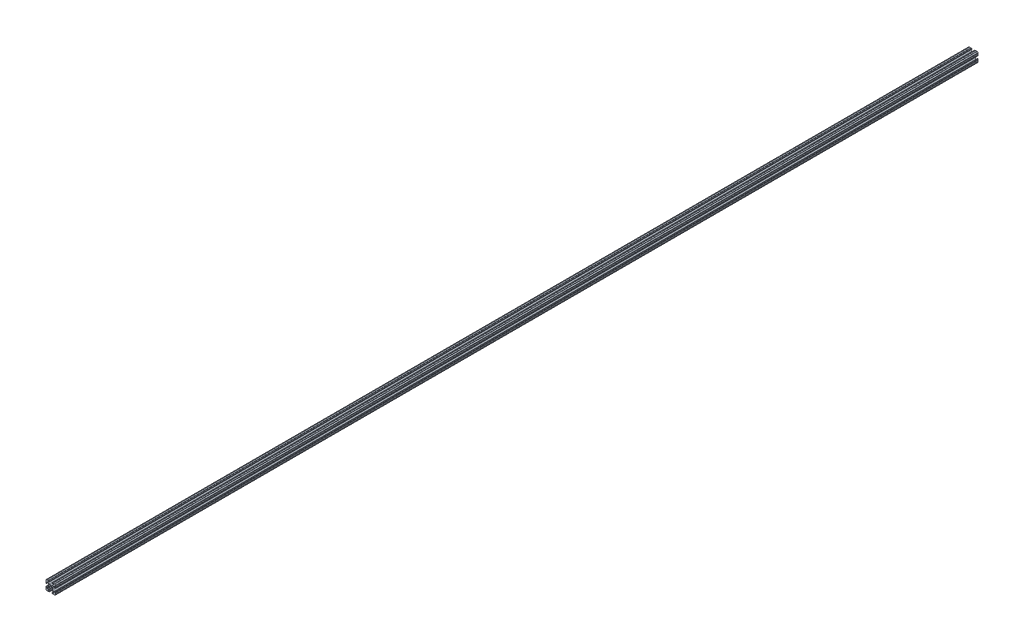
from build123d import *

# Parameters (mm, degrees)
SKETCH1_R           = 2.6035
BOSS_EXTRUDE1_DEPTH = 2463.8


with BuildPart() as part:
    # Sketch1 → Boss-Extrude1 (new body)
    with BuildSketch(Plane.XY):
        with BuildLine():
            Line((-1.709253557, -4.4958), (1.709253557, -4.4958))
            ThreePointArc((1.709253557, -4.4958), (2.922936451, -4.736929036), (3.952270251, -5.423690499))
            Line((3.952270251, -5.423690499), (7.179650497, -8.645192506))
            ThreePointArc((7.179650497, -8.645192506), (7.41473083, -9.822813117), (6.416408329, -10.4902))
            Line((6.416408329, -10.4902), (4.287512407, -10.4902))
            ThreePointArc((4.287512407, -10.4902), (3.54574862, -10.79744862), (3.2385, -11.539212407))
            Line((3.2385, -11.539212407), (3.2385, -11.650987593))
            ThreePointArc((3.2385, -11.650987593), (3.54574862, -12.39275138), (4.287512407, -12.7))
            Line((4.287512407, -12.7), (5.317126718, -12.7))
            ThreePointArc((5.317126718, -12.7), (5.825126718, -12.192), (6.333126718, -12.7))
            Line((6.333126718, -12.7), (9.550443118, -12.7))
            ThreePointArc((9.550443118, -12.7), (10.058366869, -12.192000006), (10.566443095, -12.699847501))
            ThreePointArc((10.566443095, -12.699847501), (12.082537762, -12.08250727), (12.699846982, -10.566399977))
            ThreePointArc((12.699846982, -10.566399977), (12.192000006, -10.058323491), (12.7, -9.5504))
            Line((12.7, -9.5504), (12.7, -6.3330836))
            ThreePointArc((12.7, -6.3330836), (12.192, -5.8250836), (12.7, -5.3170836))
            Line((12.7, -5.3170836), (12.7, -4.287469289))
            ThreePointArc((12.7, -4.287469289), (12.39275138, -3.545705502), (11.650987593, -3.238456882))
            Line((11.650987593, -3.238456882), (11.539212407, -3.238456882))
            ThreePointArc((11.539212407, -3.238456882), (10.79744862, -3.545705502), (10.4902, -4.287469289))
            Line((10.4902, -4.287469289), (10.4902, -6.402089023))
            ThreePointArc((10.4902, -6.402089023), (9.856505071, -7.351067942), (8.737131347, -7.129408934))
            Line((8.737131347, -7.129408934), (5.441005833, -3.840816462))
            ThreePointArc((5.441005833, -3.840816462), (4.750877967, -2.809883091), (4.5085, -1.593185507))
            Line((4.5085, -1.593185507), (4.5085, 1.593185507))
            ThreePointArc((4.5085, 1.593185507), (4.750877967, 2.809883091), (5.441005833, 3.840816462))
            Line((5.441005833, 3.840816462), (8.737131347, 7.129408934))
            ThreePointArc((8.737131347, 7.129408934), (9.856505071, 7.351067942), (10.4902, 6.402089023))
            Line((10.4902, 6.402089023), (10.4902, 4.287469289))
            ThreePointArc((10.4902, 4.287469289), (10.79744862, 3.545705502), (11.539212407, 3.238456882))
            Line((11.539212407, 3.238456882), (11.650987593, 3.238456882))
            ThreePointArc((11.650987593, 3.238456882), (12.39275138, 3.545705502), (12.7, 4.287469289))
            Line((12.7, 4.287469289), (12.7, 5.3170836))
            ThreePointArc((12.7, 5.3170836), (12.192, 5.8250836), (12.7, 6.3330836))
            Line((12.7, 6.3330836), (12.7, 9.5504))
            ThreePointArc((12.7, 9.5504), (12.192000006, 10.058323491), (12.699846982, 10.566399977))
            ThreePointArc((12.699846982, 10.566399977), (12.082537762, 12.08250727), (10.566443095, 12.699847501))
            ThreePointArc((10.566443095, 12.699847501), (10.058366869, 12.192000006), (9.550443118, 12.7))
            Line((9.550443118, 12.7), (6.333126718, 12.7))
            ThreePointArc((6.333126718, 12.7), (5.825126718, 12.192), (5.317126718, 12.7))
            Line((5.317126718, 12.7), (4.287512407, 12.7))
            ThreePointArc((4.287512407, 12.7), (3.54574862, 12.39275138), (3.2385, 11.650987593))
            Line((3.2385, 11.650987593), (3.2385, 11.539212407))
            ThreePointArc((3.2385, 11.539212407), (3.54574862, 10.79744862), (4.287512407, 10.4902))
            Line((4.287512407, 10.4902), (6.476788598, 10.4902))
            ThreePointArc((6.476788598, 10.4902), (7.432222385, 9.85140422), (7.207036008, 8.724370562))
            Line((7.207036008, 8.724370562), (3.898272566, 5.423169045))
            ThreePointArc((3.898272566, 5.423169045), (2.869120213, 4.736787962), (1.655778399, 4.4958))
            Line((1.655778399, 4.4958), (-1.655778399, 4.4958))
            ThreePointArc((-1.655778399, 4.4958), (-2.869120213, 4.736787962), (-3.898272566, 5.423169045))
            Line((-3.898272566, 5.423169045), (-7.207036008, 8.724370562))
            ThreePointArc((-7.207036008, 8.724370562), (-7.432222385, 9.85140422), (-6.476788598, 10.4902))
            Line((-6.476788598, 10.4902), (-4.287512407, 10.4902))
            ThreePointArc((-4.287512407, 10.4902), (-3.54574862, 10.79744862), (-3.2385, 11.539212407))
            Line((-3.2385, 11.539212407), (-3.2385, 11.650987593))
            ThreePointArc((-3.2385, 11.650987593), (-3.54574862, 12.39275138), (-4.287512407, 12.7))
            Line((-4.287512407, 12.7), (-5.317126718, 12.7))
            ThreePointArc((-5.317126718, 12.7), (-5.825126718, 12.192), (-6.333126718, 12.7))
            Line((-6.333126718, 12.7), (-9.550443118, 12.7))
            ThreePointArc((-9.550443118, 12.7), (-10.058366869, 12.192000006), (-10.566443095, 12.699847501))
            ThreePointArc((-10.566443095, 12.699847501), (-12.082537762, 12.08250727), (-12.699846982, 10.566399977))
            ThreePointArc((-12.699846982, 10.566399977), (-12.192000006, 10.058323491), (-12.7, 9.5504))
            Line((-12.7, 9.5504), (-12.7, 6.3330836))
            ThreePointArc((-12.7, 6.3330836), (-12.192, 5.8250836), (-12.7, 5.3170836))
            Line((-12.7, 5.3170836), (-12.7, 4.287469289))
            ThreePointArc((-12.7, 4.287469289), (-12.39275138, 3.545705502), (-11.650987593, 3.238456882))
            Line((-11.650987593, 3.238456882), (-11.539212407, 3.238456882))
            ThreePointArc((-11.539212407, 3.238456882), (-10.79744862, 3.545705502), (-10.4902, 4.287469289))
            Line((-10.4902, 4.287469289), (-10.4902, 6.402089023))
            ThreePointArc((-10.4902, 6.402089023), (-9.856505071, 7.351067942), (-8.737131347, 7.129408934))
            Line((-8.737131347, 7.129408934), (-5.441005833, 3.840816462))
            ThreePointArc((-5.441005833, 3.840816462), (-4.750877967, 2.809883091), (-4.5085, 1.593185507))
            Line((-4.5085, 1.593185507), (-4.5085, -1.593185507))
            ThreePointArc((-4.5085, -1.593185507), (-4.750877967, -2.809883091), (-5.441005833, -3.840816462))
            Line((-5.441005833, -3.840816462), (-8.737131347, -7.129408934))
            ThreePointArc((-8.737131347, -7.129408934), (-9.856505071, -7.351067942), (-10.4902, -6.402089023))
            Line((-10.4902, -6.402089023), (-10.4902, -4.287469289))
            ThreePointArc((-10.4902, -4.287469289), (-10.79744862, -3.545705502), (-11.539212407, -3.238456882))
            Line((-11.539212407, -3.238456882), (-11.650987593, -3.238456882))
            ThreePointArc((-11.650987593, -3.238456882), (-12.39275138, -3.545705502), (-12.7, -4.287469289))
            Line((-12.7, -4.287469289), (-12.7, -5.3170836))
            ThreePointArc((-12.7, -5.3170836), (-12.192, -5.8250836), (-12.7, -6.3330836))
            Line((-12.7, -6.3330836), (-12.7, -9.5504))
            ThreePointArc((-12.7, -9.5504), (-12.192000006, -10.058323491), (-12.699846982, -10.566399977))
            ThreePointArc((-12.699846982, -10.566399977), (-12.082537762, -12.08250727), (-10.566443095, -12.699847501))
            ThreePointArc((-10.566443095, -12.699847501), (-10.058366869, -12.192000006), (-9.550443118, -12.7))
            Line((-9.550443118, -12.7), (-6.333126718, -12.7))
            ThreePointArc((-6.333126718, -12.7), (-5.825126718, -12.192), (-5.317126718, -12.7))
            Line((-5.317126718, -12.7), (-4.287512407, -12.7))
            ThreePointArc((-4.287512407, -12.7), (-3.54574862, -12.39275138), (-3.2385, -11.650987593))
            Line((-3.2385, -11.650987593), (-3.2385, -11.539212407))
            ThreePointArc((-3.2385, -11.539212407), (-3.54574862, -10.79744862), (-4.287512407, -10.4902))
            Line((-4.287512407, -10.4902), (-6.416408329, -10.4902))
            ThreePointArc((-6.416408329, -10.4902), (-7.41473083, -9.822813117), (-7.179650497, -8.645192506))
            Line((-7.179650497, -8.645192506), (-3.952270251, -5.423690499))
            ThreePointArc((-3.952270251, -5.423690499), (-2.922936451, -4.736929036), (-1.709253557, -4.4958))
        make_face()
        Circle(SKETCH1_R, mode=Mode.SUBTRACT)
    extrude(amount=BOSS_EXTRUDE1_DEPTH)


solid = part.part
